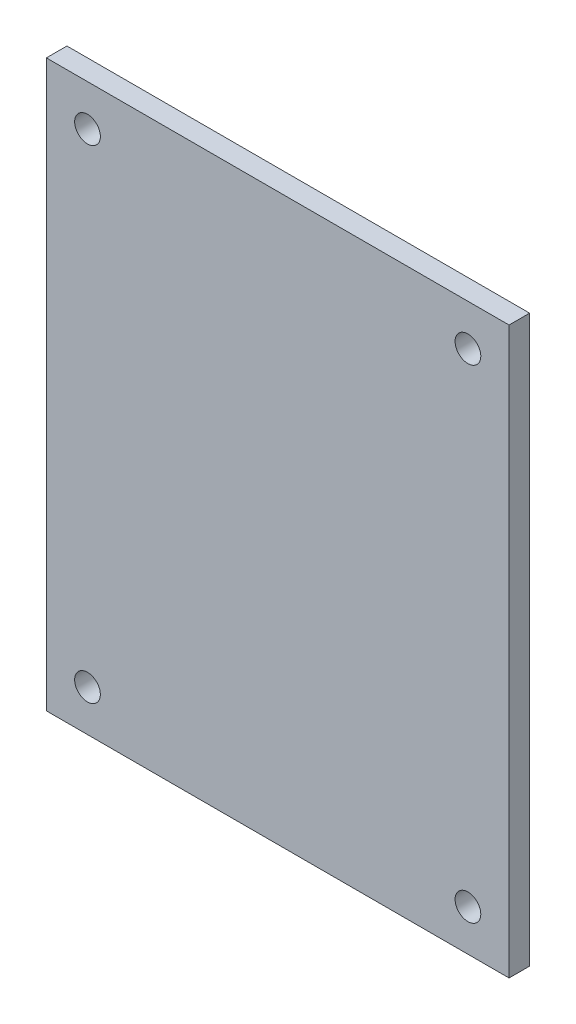
from build123d import *

# Parameters (mm, degrees)
CROQUIS1_W              = 45
CROQUIS1_H              = 55
CROQUIS1_R              = 1.25
SALIENTE_EXTRUIR1_DEPTH = 2


with BuildPart() as part:
    # Croquis1 → Saliente-Extruir1 (new body)
    with BuildSketch(Plane.XY):
        Rectangle(CROQUIS1_W, CROQUIS1_H)
        with Locations((-18.5, 23.5)):
            Circle(CROQUIS1_R, mode=Mode.SUBTRACT)
        with Locations((18.5, 23.5)):
            Circle(CROQUIS1_R, mode=Mode.SUBTRACT)
        with Locations((18.5, -23.5)):
            Circle(CROQUIS1_R, mode=Mode.SUBTRACT)
        with Locations((-18.5, -23.5)):
            Circle(CROQUIS1_R, mode=Mode.SUBTRACT)
    extrude(amount=SALIENTE_EXTRUIR1_DEPTH)


solid = part.part
